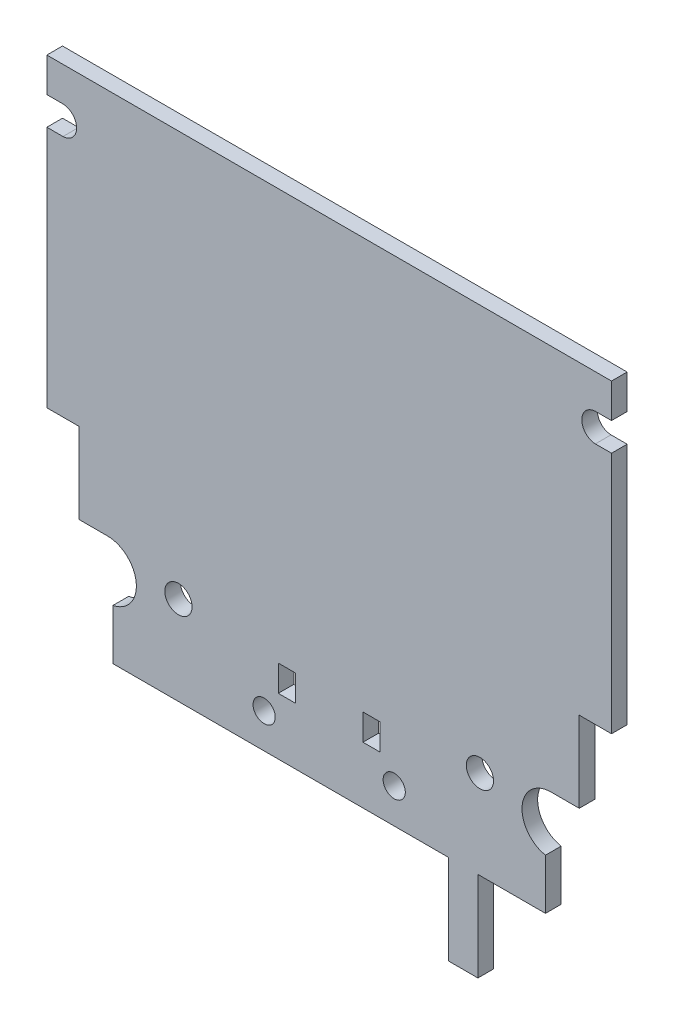
from build123d import *

# Parameters (mm, degrees)
SKIZZE1_R                       = 1.35
SKIZZE1_R_2                     = 1.1
SKIZZE1_W                       = 1.7
SKIZZE1_H                       = 2.6
AUFSATZ_LINEAR_AUSTRAGEN1_DEPTH = 1.55


with BuildPart() as part:
    # Skizze1 → Aufsatz-Linear austragen1 (new body)
    with BuildSketch(Plane.XY):
        with BuildLine():
            Line((-28, 23.303403096), (-28, 26.703403096))
            Line((-28, 26.703403096), (28, 26.703403096))
            Line((28, 26.703403096), (28, 23.303403096))
            Line((28, 23.303403096), (26.4, 23.303403096))
            ThreePointArc((26.4, 23.303403096), (25.05, 21.903403096), (26.4, 20.503403096))
            Line((26.4, 20.503403096), (28, 20.503403096))
            Line((28, 20.503403096), (28, -3.596596904))
            Line((28, -3.596596904), (24.8, -3.596596904))
            Line((24.8, -3.596596904), (24.8, -11.596596904))
            Line((24.8, -11.596596904), (22, -11.596596904))
            ThreePointArc((22, -11.596596904), (19.136763195, -14.196854756), (21.45, -17.296596904))
            Line((21.45, -17.296596904), (21.45, -22.296596904))
            Line((21.45, -22.296596904), (14.75, -22.296596904))
            Line((14.75, -22.296596904), (14.75, -31.196596904))
            Line((14.75, -31.196596904), (11.85, -31.196596904))
            Line((11.85, -31.196596904), (11.85, -22.296596904))
            Line((11.85, -22.296596904), (-21.45, -22.296596904))
            Line((-21.45, -22.296596904), (-21.45, -17.296596904))
            ThreePointArc((-21.45, -17.296596904), (-19.136763195, -14.196854756), (-22, -11.596596904))
            Line((-22, -11.596596904), (-24.8, -11.596596904))
            Line((-24.8, -11.596596904), (-24.8, -3.596596904))
            Line((-24.8, -3.596596904), (-28, -3.596596904))
            Line((-28, -3.596596904), (-28, 20.503403096))
            Line((-28, 20.503403096), (-26.4, 20.503403096))
            ThreePointArc((-26.4, 20.503403096), (-25.05, 21.903403096), (-26.4, 23.303403096))
            Line((-26.4, 23.303403096), (-28, 23.303403096))
        make_face()
        with Locations((14.95, -13.496596904)):
            Circle(SKIZZE1_R, mode=Mode.SUBTRACT)
        with Locations((-14.95, -13.496596904)):
            Circle(SKIZZE1_R, mode=Mode.SUBTRACT)
        with Locations((6.45, -18.852047487)):
            Circle(SKIZZE1_R_2, mode=Mode.SUBTRACT)
        with Locations((-6.45, -18.852047487)):
            Circle(SKIZZE1_R_2, mode=Mode.SUBTRACT)
        with Locations((-4.2, -15.345681582)):
            Rectangle(SKIZZE1_W, SKIZZE1_H, mode=Mode.SUBTRACT)
        with Locations((4.2, -15.345681582)):
            Rectangle(SKIZZE1_W, SKIZZE1_H, mode=Mode.SUBTRACT)
    extrude(amount=AUFSATZ_LINEAR_AUSTRAGEN1_DEPTH)


solid = part.part
